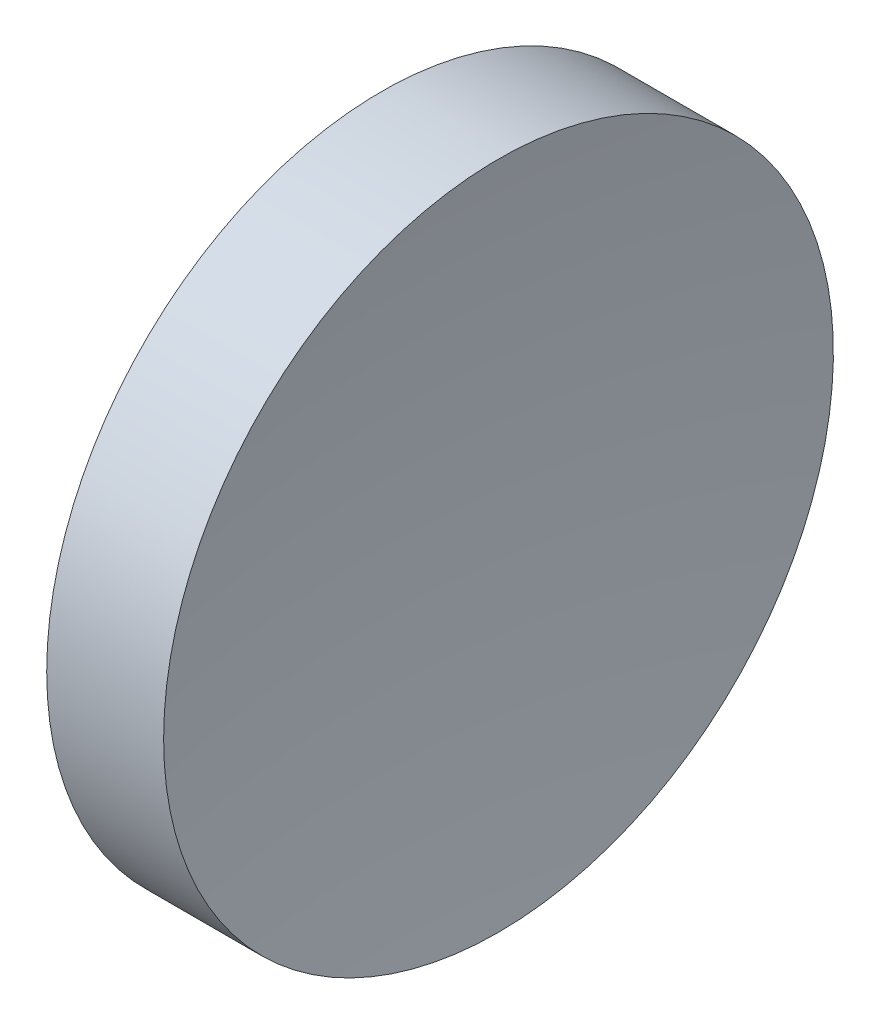
from build123d import *


with BuildPart() as part:
    # 草图1 → 旋转1 (revolve)
    with BuildSketch(Plane.XY, mode=Mode.PRIVATE) as revolve_1_sk:
        with BuildLine():
            Line((119.506834179, 71.193989087), (119.506834179, 83.893989087))
            Line((119.506834179, 83.893989087), (123.940950383, 83.893989087))
            ThreePointArc((123.940950383, 83.893989087), (123.240678224, 77.561142553), (123.006834179, 71.193989087))
            Line((123.006834179, 71.193989087), (119.506834179, 71.193989087))
        make_face()
    revolve(revolve_1_sk.sketch.rotate(Axis((111.955229758, 71.193989087, 0), (1, 0, 0)), 180), axis=Axis((111.955229758, 71.193989087, 0), (1, 0, 0)))  # turned: the seam where the file's is


solid = part.part
